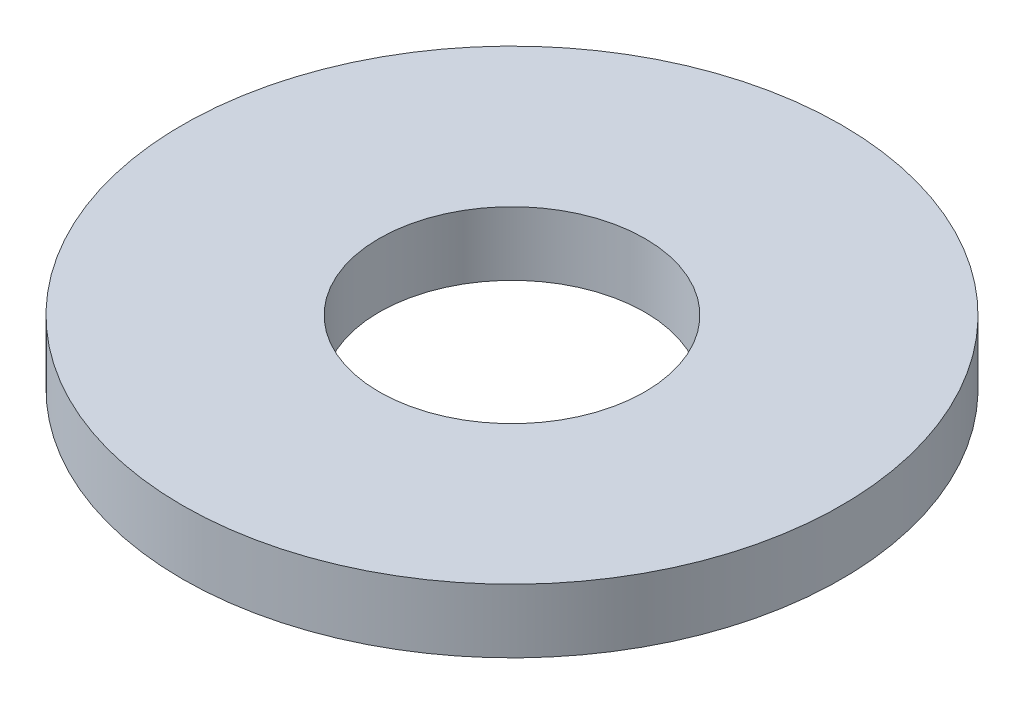
from build123d import *

# Parameters (mm, degrees)
SKETCH1_R           = 3.937
SKETCH1_R_2         = 1.5875
BOSS_EXTRUDE1_DEPTH = 0.762


with BuildPart() as part:
    # Sketch1 → Boss-Extrude1 (new body)
    with BuildSketch(Plane(origin=(0, 0, 0), x_dir=(1, 0, 0), z_dir=(0, 1, 0))):
        Circle(SKETCH1_R)
        Circle(SKETCH1_R_2, mode=Mode.SUBTRACT)
    extrude(amount=BOSS_EXTRUDE1_DEPTH)


solid = part.part
